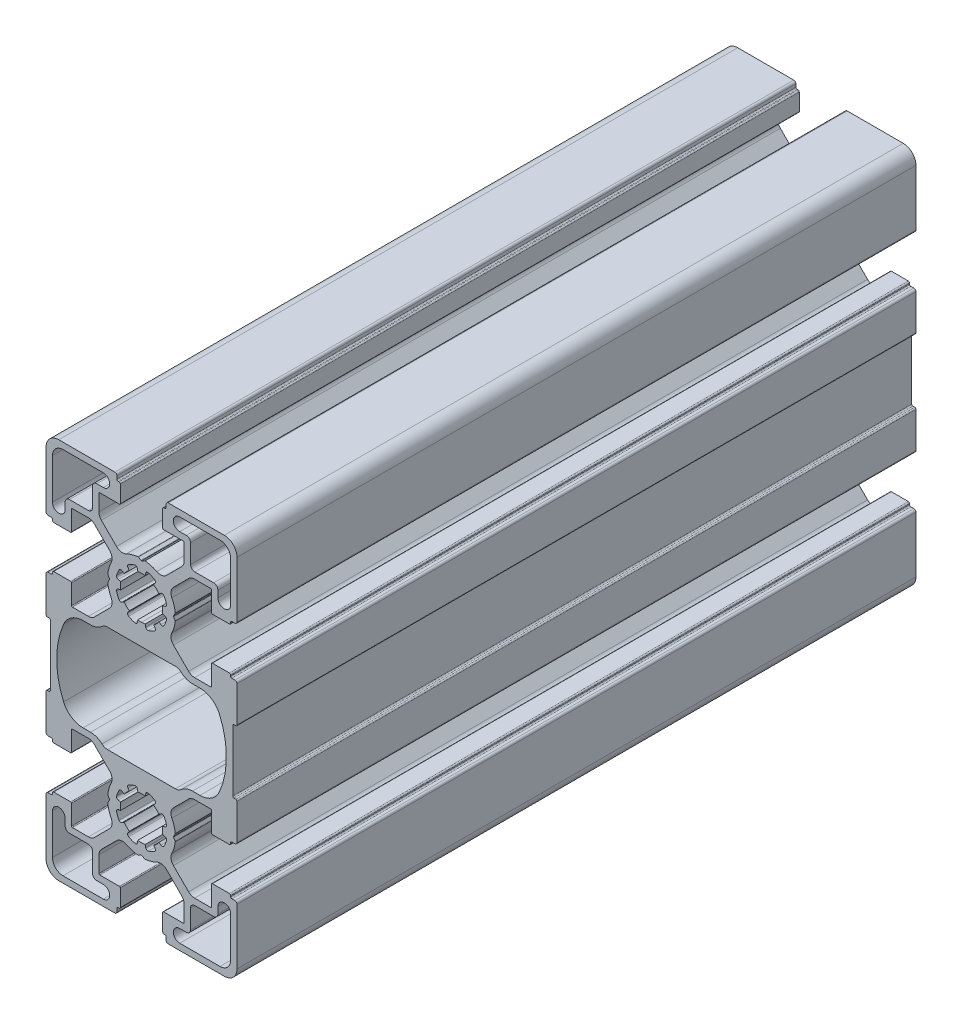
from build123d import *

# Parameters (mm, degrees)
BASE_EXTRUDE_DEPTH = 160


with BuildPart() as part:
    # Sketch1 → Base-Extrude (new body)
    with BuildSketch(Plane.XY):
        with BuildLine():
            Line((-0.740836116, 30.427758634), (-0.102763251, 30.059367406))
            ThreePointArc((-0.102763251, 30.059367406), (-0.053312326, 30.038169391), (0, 30.030920546))
            ThreePointArc((0, 30.030920546), (0.053312326, 30.038169391), (0.102763251, 30.059367406))
            Line((0.102763251, 30.059367406), (0.740836116, 30.427758634))
            ThreePointArc((0.740836116, 30.427758634), (0.799576237, 30.450250726), (0.86239711, 30.453386662))
            ThreePointArc((0.86239711, 30.453386662), (2.260568883, 30.173971094), (3.586933491, 29.650793982))
            ThreePointArc((3.586933491, 29.650793982), (4.802749757, 29.46409935), (5.897874663, 30.024247115))
            Line((5.897874663, 30.024247115), (9.464166852, 33.590539926))
            ThreePointArc((9.464166852, 33.590539926), (9.897712372, 34.239387492), (10.049953531, 35.004755059))
            Line((10.049953531, 35.004755059), (10.049953531, 38.799984208))
            ThreePointArc((10.049953531, 38.799984208), (9.991374345, 38.941406873), (9.84995168, 38.999986059))
            Line((9.84995168, 38.999986059), (5.199960681, 38.999986059))
            ThreePointArc((5.199960681, 38.999986059), (5.058538016, 39.058565245), (4.99995883, 39.199987909))
            Line((4.99995883, 39.199987909), (4.99995883, 43.199989085))
            ThreePointArc((4.99995883, 43.199989085), (5.087825998, 43.412119193), (5.299956106, 43.499986361))
            Line((5.299956106, 43.499986361), (5.499944988, 43.499986361))
            ThreePointArc((5.499944988, 43.499986361), (5.71207757, 43.587854553), (5.799945763, 43.799987136))
            Line((5.799945763, 43.799987136), (5.799945763, 44.500009803))
            ThreePointArc((5.799945763, 44.500009803), (5.946392263, 44.85356293), (6.29994539, 45.00000943))
            Line((6.29994539, 45.00000943), (19.499955001, 45.00000943))
            ThreePointArc((19.499955001, 45.00000943), (21.62127376, 44.12133043), (22.49995276, 42.000011671))
            Line((22.49995276, 42.000011671), (22.49995276, 28.79998913))
            ThreePointArc((22.49995276, 28.79998913), (22.353506233, 28.446435977), (21.999953058, 28.299989504))
            Line((21.999953058, 28.299989504), (21.299938888, 28.29998961))
            ThreePointArc((21.299938888, 28.29998961), (21.087805922, 28.212121287), (20.999937567, 27.999988334))
            Line((20.999937567, 27.999988334), (20.999937567, 27.799995477))
            ThreePointArc((20.999937567, 27.799995477), (20.912069081, 27.587862187), (20.699935791, 27.499993701))
            Line((20.699935791, 27.499993701), (16.699935313, 27.499993701))
            ThreePointArc((16.699935313, 27.499993701), (16.558515235, 27.558571815), (16.499937121, 27.699991893))
            Line((16.499937121, 27.699991893), (16.499937121, 32.34998995))
            ThreePointArc((16.499937121, 32.34998995), (16.441358961, 32.49141014), (16.299938771, 32.549988301))
            Line((16.299938771, 32.549988301), (12.504708373, 32.549988301))
            ThreePointArc((12.504708373, 32.549988301), (11.739340597, 32.397747212), (11.090493085, 31.964201264))
            Line((11.090493085, 31.964201264), (7.524203235, 28.397912415))
            ThreePointArc((7.524203235, 28.397912415), (6.964033778, 27.302784051), (7.150720073, 26.086953396))
            ThreePointArc((7.150720073, 26.086953396), (7.673896729, 24.760597365), (7.953313252, 23.362434091))
            ThreePointArc((7.953313252, 23.362434091), (7.950176411, 23.299610003), (7.927682437, 23.240867116))
            Line((7.927682437, 23.240867116), (7.557669192, 22.599991424))
            ThreePointArc((7.557669192, 22.599991424), (7.530873485, 22.4999893), (7.557669192, 22.399987177))
            Line((7.557669192, 22.399987177), (7.927682978, 21.759110548))
            ThreePointArc((7.927682978, 21.759110548), (7.9501755, 21.700371448), (7.953312133, 21.637551412))
            ThreePointArc((7.953312133, 21.637551412), (7.673894832, 20.239384934), (7.150716902, 18.913025864))
            ThreePointArc((7.150716902, 18.913025864), (6.964030761, 17.697197224), (7.524198948, 16.602070473))
            Line((7.524198948, 16.602070473), (11.090489343, 13.035778079))
            ThreePointArc((11.090489343, 13.035778079), (11.739337223, 12.602231588), (12.504705581, 12.449990301))
            Line((12.504705581, 12.449990301), (16.299936771, 12.449990301))
            ThreePointArc((16.299936771, 12.449990301), (16.441358375, 12.508569047), (16.499937121, 12.649990651))
            Line((16.499937121, 12.649990651), (16.499937121, 17.29998595))
            ThreePointArc((16.499937121, 17.29998595), (16.558515575, 17.441406847), (16.699936472, 17.499985301))
            Line((16.699936472, 17.499985301), (20.699937845, 17.499985301))
            ThreePointArc((20.699937845, 17.499985301), (20.912069392, 17.412117523), (20.999937121, 17.199985957))
            Line((20.999937121, 17.199985957), (20.999937076, 16.999997645))
            ThreePointArc((20.999937076, 16.999997645), (21.087804805, 16.787866078), (21.299936352, 16.699998301))
            Line((21.299936352, 16.699998301), (21.999952596, 16.699998301))
            ThreePointArc((21.999952596, 16.699998301), (22.353506326, 16.553551551), (22.499953076, 16.199997821))
            Line((22.499953076, 16.199997821), (22.499953076, 7.799999276))
            ThreePointArc((22.499953076, 7.799999276), (22.412085322, 7.587867754), (22.1999538, 7.5))
            Line((22.1999538, 7.5), (21.799954836, 7.5))
            ThreePointArc((21.799954836, 7.5), (21.58782296, 7.4121321), (21.49995506, 7.200000224))
            Line((21.49995506, 7.200000224), (21.49995506, -7.200000224))
            ThreePointArc((21.49995506, -7.200000224), (21.58782296, -7.4121321), (21.799954836, -7.5))
            Line((21.799954836, -7.5), (22.1999538, -7.5))
            ThreePointArc((22.1999538, -7.5), (22.412085322, -7.587867754), (22.499953076, -7.799999276))
            Line((22.499953076, -7.799999276), (22.499953076, -16.199997821))
            ThreePointArc((22.499953076, -16.199997821), (22.353506326, -16.553551551), (21.999952596, -16.699998301))
            Line((21.999952596, -16.699998301), (21.299936352, -16.699998301))
            ThreePointArc((21.299936352, -16.699998301), (21.087804805, -16.787866078), (20.999937076, -16.999997645))
            Line((20.999937076, -16.999997645), (20.999937121, -17.199985957))
            ThreePointArc((20.999937121, -17.199985957), (20.912069392, -17.412117523), (20.699937845, -17.499985301))
            Line((20.699937845, -17.499985301), (16.699936472, -17.499985301))
            ThreePointArc((16.699936472, -17.499985301), (16.558515575, -17.441406847), (16.499937121, -17.29998595))
            Line((16.499937121, -17.29998595), (16.499937121, -12.649990651))
            ThreePointArc((16.499937121, -12.649990651), (16.441358375, -12.508569047), (16.299936771, -12.449990301))
            Line((16.299936771, -12.449990301), (12.504705581, -12.449990301))
            ThreePointArc((12.504705581, -12.449990301), (11.739337223, -12.602231588), (11.090489343, -13.035778079))
            Line((11.090489343, -13.035778079), (7.524198948, -16.602070473))
            ThreePointArc((7.524198948, -16.602070473), (6.964030761, -17.697197224), (7.150716902, -18.913025864))
            ThreePointArc((7.150716902, -18.913025864), (7.673894832, -20.239384934), (7.953312133, -21.637551412))
            ThreePointArc((7.953312133, -21.637551412), (7.9501755, -21.700371448), (7.927682978, -21.759110548))
            Line((7.927682978, -21.759110548), (7.557669192, -22.399987177))
            ThreePointArc((7.557669192, -22.399987177), (7.530873485, -22.4999893), (7.557669192, -22.599991424))
            Line((7.557669192, -22.599991424), (7.927682437, -23.240867116))
            ThreePointArc((7.927682437, -23.240867116), (7.950176411, -23.299610003), (7.953313252, -23.362434091))
            ThreePointArc((7.953313252, -23.362434091), (7.673896729, -24.760597365), (7.150720073, -26.086953396))
            ThreePointArc((7.150720073, -26.086953396), (6.964033778, -27.302784051), (7.524203235, -28.397912415))
            Line((7.524203235, -28.397912415), (11.090493085, -31.964201264))
            ThreePointArc((11.090493085, -31.964201264), (11.739340597, -32.397747212), (12.504708373, -32.549988301))
            Line((12.504708373, -32.549988301), (16.299938771, -32.549988301))
            ThreePointArc((16.299938771, -32.549988301), (16.441358961, -32.49141014), (16.499937121, -32.34998995))
            Line((16.499937121, -32.34998995), (16.499937121, -27.699991893))
            ThreePointArc((16.499937121, -27.699991893), (16.558515235, -27.558571815), (16.699935313, -27.499993701))
            Line((16.699935313, -27.499993701), (20.699935791, -27.499993701))
            ThreePointArc((20.699935791, -27.499993701), (20.912069081, -27.587862187), (20.999937567, -27.799995477))
            Line((20.999937567, -27.799995477), (20.999937567, -27.999988334))
            ThreePointArc((20.999937567, -27.999988334), (21.087805922, -28.212121287), (21.299938888, -28.29998961))
            Line((21.299938888, -28.29998961), (21.999953058, -28.299989504))
            ThreePointArc((21.999953058, -28.299989504), (22.353506233, -28.446435977), (22.49995276, -28.79998913))
            Line((22.49995276, -28.79998913), (22.49995276, -42.000011671))
            ThreePointArc((22.49995276, -42.000011671), (21.62127376, -44.12133043), (19.499955001, -45.00000943))
            Line((19.499955001, -45.00000943), (6.29994539, -45.00000943))
            ThreePointArc((6.29994539, -45.00000943), (5.946392263, -44.85356293), (5.799945763, -44.500009803))
            Line((5.799945763, -44.500009803), (5.799945763, -43.799987136))
            ThreePointArc((5.799945763, -43.799987136), (5.71207757, -43.587854553), (5.499944988, -43.499986361))
            Line((5.499944988, -43.499986361), (5.299956106, -43.499986361))
            ThreePointArc((5.299956106, -43.499986361), (5.087825998, -43.412119193), (4.99995883, -43.199989085))
            Line((4.99995883, -43.199989085), (4.99995883, -39.199987909))
            ThreePointArc((4.99995883, -39.199987909), (5.058538016, -39.058565245), (5.199960681, -38.999986059))
            Line((5.199960681, -38.999986059), (9.84995168, -38.999986059))
            ThreePointArc((9.84995168, -38.999986059), (9.991374345, -38.941406873), (10.049953531, -38.799984208))
            Line((10.049953531, -38.799984208), (10.049953531, -35.004755059))
            ThreePointArc((10.049953531, -35.004755059), (9.897712372, -34.239387492), (9.464166852, -33.590539926))
            Line((9.464166852, -33.590539926), (5.897874663, -30.024247115))
            ThreePointArc((5.897874663, -30.024247115), (4.802749757, -29.46409935), (3.586933491, -29.650793982))
            ThreePointArc((3.586933491, -29.650793982), (2.260568883, -30.173971094), (0.86239711, -30.453386662))
            ThreePointArc((0.86239711, -30.453386662), (0.799576237, -30.450250726), (0.740836116, -30.427758634))
            Line((0.740836116, -30.427758634), (0.102763251, -30.059367406))
            ThreePointArc((0.102763251, -30.059367406), (0.053312326, -30.038169391), (0, -30.030920546))
            ThreePointArc((0, -30.030920546), (-0.053312326, -30.038169391), (-0.102763251, -30.059367406))
            Line((-0.102763251, -30.059367406), (-0.740836116, -30.427758634))
            ThreePointArc((-0.740836116, -30.427758634), (-0.799576237, -30.450250726), (-0.86239711, -30.453386662))
            ThreePointArc((-0.86239711, -30.453386662), (-2.260568883, -30.173971094), (-3.586933491, -29.650793982))
            ThreePointArc((-3.586933491, -29.650793982), (-4.802749757, -29.46409935), (-5.897874663, -30.024247115))
            Line((-5.897874663, -30.024247115), (-9.464166852, -33.590539926))
            ThreePointArc((-9.464166852, -33.590539926), (-9.897712372, -34.239387492), (-10.049953531, -35.004755059))
            Line((-10.049953531, -35.004755059), (-10.049953531, -38.799984208))
            ThreePointArc((-10.049953531, -38.799984208), (-9.991374345, -38.941406873), (-9.84995168, -38.999986059))
            Line((-9.84995168, -38.999986059), (-5.199960681, -38.999986059))
            ThreePointArc((-5.199960681, -38.999986059), (-5.058538016, -39.058565245), (-4.99995883, -39.199987909))
            Line((-4.99995883, -39.199987909), (-4.99995883, -43.199989085))
            ThreePointArc((-4.99995883, -43.199989085), (-5.087825998, -43.412119193), (-5.299956106, -43.499986361))
            Line((-5.299956106, -43.499986361), (-5.499944988, -43.499986361))
            ThreePointArc((-5.499944988, -43.499986361), (-5.71207757, -43.587854553), (-5.799945763, -43.799987136))
            Line((-5.799945763, -43.799987136), (-5.799945763, -44.500009803))
            ThreePointArc((-5.799945763, -44.500009803), (-5.946392263, -44.85356293), (-6.29994539, -45.00000943))
            Line((-6.29994539, -45.00000943), (-19.499955001, -45.00000943))
            ThreePointArc((-19.499955001, -45.00000943), (-21.62127376, -44.12133043), (-22.49995276, -42.000011671))
            Line((-22.49995276, -42.000011671), (-22.49995276, -28.79998913))
            ThreePointArc((-22.49995276, -28.79998913), (-22.353506233, -28.446435977), (-21.999953058, -28.299989504))
            Line((-21.999953058, -28.299989504), (-21.299938888, -28.29998961))
            ThreePointArc((-21.299938888, -28.29998961), (-21.087805922, -28.212121287), (-20.999937567, -27.999988334))
            Line((-20.999937567, -27.999988334), (-20.999937567, -27.799995477))
            ThreePointArc((-20.999937567, -27.799995477), (-20.912069081, -27.587862187), (-20.699935791, -27.499993701))
            Line((-20.699935791, -27.499993701), (-16.699935313, -27.499993701))
            ThreePointArc((-16.699935313, -27.499993701), (-16.558515235, -27.558571815), (-16.499937121, -27.699991893))
            Line((-16.499937121, -27.699991893), (-16.499937121, -32.34998995))
            ThreePointArc((-16.499937121, -32.34998995), (-16.441358961, -32.49141014), (-16.299938771, -32.549988301))
            Line((-16.299938771, -32.549988301), (-12.504708373, -32.549988301))
            ThreePointArc((-12.504708373, -32.549988301), (-11.739340597, -32.397747212), (-11.090493085, -31.964201264))
            Line((-11.090493085, -31.964201264), (-7.524203235, -28.397912415))
            ThreePointArc((-7.524203235, -28.397912415), (-6.964033778, -27.302784051), (-7.150720073, -26.086953396))
            ThreePointArc((-7.150720073, -26.086953396), (-7.673896729, -24.760597365), (-7.953313252, -23.362434091))
            ThreePointArc((-7.953313252, -23.362434091), (-7.950176411, -23.299610003), (-7.927682437, -23.240867116))
            Line((-7.927682437, -23.240867116), (-7.557669192, -22.599991424))
            ThreePointArc((-7.557669192, -22.599991424), (-7.530873485, -22.4999893), (-7.557669192, -22.399987177))
            Line((-7.557669192, -22.399987177), (-7.927682978, -21.759110548))
            ThreePointArc((-7.927682978, -21.759110548), (-7.9501755, -21.700371448), (-7.953312133, -21.637551412))
            ThreePointArc((-7.953312133, -21.637551412), (-7.673894832, -20.239384934), (-7.150716902, -18.913025864))
            ThreePointArc((-7.150716902, -18.913025864), (-6.964030761, -17.697197224), (-7.524198948, -16.602070473))
            Line((-7.524198948, -16.602070473), (-11.090489343, -13.035778079))
            ThreePointArc((-11.090489343, -13.035778079), (-11.739337223, -12.602231588), (-12.504705581, -12.449990301))
            Line((-12.504705581, -12.449990301), (-16.299936771, -12.449990301))
            ThreePointArc((-16.299936771, -12.449990301), (-16.441358375, -12.508569047), (-16.499937121, -12.649990651))
            Line((-16.499937121, -12.649990651), (-16.499937121, -17.29998595))
            ThreePointArc((-16.499937121, -17.29998595), (-16.558515575, -17.441406847), (-16.699936472, -17.499985301))
            Line((-16.699936472, -17.499985301), (-20.699937845, -17.499985301))
            ThreePointArc((-20.699937845, -17.499985301), (-20.912069392, -17.412117523), (-20.999937121, -17.199985957))
            Line((-20.999937121, -17.199985957), (-20.999937076, -16.999997645))
            ThreePointArc((-20.999937076, -16.999997645), (-21.087804805, -16.787866078), (-21.299936352, -16.699998301))
            Line((-21.299936352, -16.699998301), (-21.999952596, -16.699998301))
            ThreePointArc((-21.999952596, -16.699998301), (-22.353506326, -16.553551551), (-22.499953076, -16.199997821))
            Line((-22.499953076, -16.199997821), (-22.499953076, -7.799999276))
            ThreePointArc((-22.499953076, -7.799999276), (-22.412085322, -7.587867754), (-22.1999538, -7.5))
            Line((-22.1999538, -7.5), (-21.799954836, -7.5))
            ThreePointArc((-21.799954836, -7.5), (-21.58782296, -7.4121321), (-21.49995506, -7.200000224))
            Line((-21.49995506, -7.200000224), (-21.49995506, 7.200000224))
            ThreePointArc((-21.49995506, 7.200000224), (-21.58782296, 7.4121321), (-21.799954836, 7.5))
            Line((-21.799954836, 7.5), (-22.1999538, 7.5))
            ThreePointArc((-22.1999538, 7.5), (-22.412085322, 7.587867754), (-22.499953076, 7.799999276))
            Line((-22.499953076, 7.799999276), (-22.499953076, 16.199997821))
            ThreePointArc((-22.499953076, 16.199997821), (-22.353506326, 16.553551551), (-21.999952596, 16.699998301))
            Line((-21.999952596, 16.699998301), (-21.299936352, 16.699998301))
            ThreePointArc((-21.299936352, 16.699998301), (-21.087804805, 16.787866078), (-20.999937076, 16.999997645))
            Line((-20.999937076, 16.999997645), (-20.999937121, 17.199985957))
            ThreePointArc((-20.999937121, 17.199985957), (-20.912069392, 17.412117523), (-20.699937845, 17.499985301))
            Line((-20.699937845, 17.499985301), (-16.699936472, 17.499985301))
            ThreePointArc((-16.699936472, 17.499985301), (-16.558515575, 17.441406847), (-16.499937121, 17.29998595))
            Line((-16.499937121, 17.29998595), (-16.499937121, 12.649990651))
            ThreePointArc((-16.499937121, 12.649990651), (-16.441358375, 12.508569047), (-16.299936771, 12.449990301))
            Line((-16.299936771, 12.449990301), (-12.504705581, 12.449990301))
            ThreePointArc((-12.504705581, 12.449990301), (-11.739337223, 12.602231588), (-11.090489343, 13.035778079))
            Line((-11.090489343, 13.035778079), (-7.524198948, 16.602070473))
            ThreePointArc((-7.524198948, 16.602070473), (-6.964030761, 17.697197224), (-7.150716902, 18.913025864))
            ThreePointArc((-7.150716902, 18.913025864), (-7.673894832, 20.239384934), (-7.953312133, 21.637551412))
            ThreePointArc((-7.953312133, 21.637551412), (-7.9501755, 21.700371448), (-7.927682978, 21.759110548))
            Line((-7.927682978, 21.759110548), (-7.557669192, 22.399987177))
            ThreePointArc((-7.557669192, 22.399987177), (-7.530873485, 22.4999893), (-7.557669192, 22.599991424))
            Line((-7.557669192, 22.599991424), (-7.927682437, 23.240867116))
            ThreePointArc((-7.927682437, 23.240867116), (-7.950176411, 23.299610003), (-7.953313252, 23.362434091))
            ThreePointArc((-7.953313252, 23.362434091), (-7.673896729, 24.760597365), (-7.150720073, 26.086953396))
            ThreePointArc((-7.150720073, 26.086953396), (-6.964033778, 27.302784051), (-7.524203235, 28.397912415))
            Line((-7.524203235, 28.397912415), (-11.090493085, 31.964201264))
            ThreePointArc((-11.090493085, 31.964201264), (-11.739340597, 32.397747212), (-12.504708373, 32.549988301))
            Line((-12.504708373, 32.549988301), (-16.299938771, 32.549988301))
            ThreePointArc((-16.299938771, 32.549988301), (-16.441358961, 32.49141014), (-16.499937121, 32.34998995))
            Line((-16.499937121, 32.34998995), (-16.499937121, 27.699991893))
            ThreePointArc((-16.499937121, 27.699991893), (-16.558515235, 27.558571815), (-16.699935313, 27.499993701))
            Line((-16.699935313, 27.499993701), (-20.699935791, 27.499993701))
            ThreePointArc((-20.699935791, 27.499993701), (-20.912069081, 27.587862187), (-20.999937567, 27.799995477))
            Line((-20.999937567, 27.799995477), (-20.999937567, 27.999988334))
            ThreePointArc((-20.999937567, 27.999988334), (-21.087805922, 28.212121287), (-21.299938888, 28.29998961))
            Line((-21.299938888, 28.29998961), (-21.999953058, 28.299989504))
            ThreePointArc((-21.999953058, 28.299989504), (-22.353506233, 28.446435977), (-22.49995276, 28.79998913))
            Line((-22.49995276, 28.79998913), (-22.49995276, 42.000011671))
            ThreePointArc((-22.49995276, 42.000011671), (-21.62127376, 44.12133043), (-19.499955001, 45.00000943))
            Line((-19.499955001, 45.00000943), (-6.29994539, 45.00000943))
            ThreePointArc((-6.29994539, 45.00000943), (-5.946392263, 44.85356293), (-5.799945763, 44.500009803))
            Line((-5.799945763, 44.500009803), (-5.799945763, 43.799987136))
            ThreePointArc((-5.799945763, 43.799987136), (-5.71207757, 43.587854553), (-5.499944988, 43.499986361))
            Line((-5.499944988, 43.499986361), (-5.299956106, 43.499986361))
            ThreePointArc((-5.299956106, 43.499986361), (-5.087825998, 43.412119193), (-4.99995883, 43.199989085))
            Line((-4.99995883, 43.199989085), (-4.99995883, 39.199987909))
            ThreePointArc((-4.99995883, 39.199987909), (-5.058538016, 39.058565245), (-5.199960681, 38.999986059))
            Line((-5.199960681, 38.999986059), (-9.84995168, 38.999986059))
            ThreePointArc((-9.84995168, 38.999986059), (-9.991374345, 38.941406873), (-10.049953531, 38.799984208))
            Line((-10.049953531, 38.799984208), (-10.049953531, 35.004755059))
            ThreePointArc((-10.049953531, 35.004755059), (-9.897712372, 34.239387492), (-9.464166852, 33.590539926))
            Line((-9.464166852, 33.590539926), (-5.897874663, 30.024247115))
            ThreePointArc((-5.897874663, 30.024247115), (-4.802749757, 29.46409935), (-3.586933491, 29.650793982))
            ThreePointArc((-3.586933491, 29.650793982), (-2.260568883, 30.173971094), (-0.86239711, 30.453386662))
            ThreePointArc((-0.86239711, 30.453386662), (-0.799576237, 30.450250726), (-0.740836116, 30.427758634))
        make_face()
        with BuildLine():
            Line((-16.999956095, 34.049999843), (-12.549953601, 34.049999843))
            ThreePointArc((-12.549953601, 34.049999843), (-11.842847348, 34.342892843), (-11.549954348, 35.049999096))
            Line((-11.549954348, 35.049999096), (-11.549954348, 39.50000559))
            ThreePointArc((-11.549954348, 39.50000559), (-11.257061348, 40.207111843), (-10.549955095, 40.500004843))
            Line((-10.549955095, 40.500004843), (-8.999762348, 40.500004843))
            ThreePointArc((-8.999762348, 40.500004843), (-7.499762348, 42.000004843), (-8.999762348, 43.500004843))
            Line((-8.999762348, 43.500004843), (-18.499955348, 43.500004843))
            ThreePointArc((-18.499955348, 43.500004843), (-20.267722848, 42.767772343), (-20.999955348, 41.000004843))
            Line((-20.999955348, 41.000004843), (-20.999955348, 31.500004843))
            ThreePointArc((-20.999955348, 31.500004843), (-19.499955348, 30.000004843), (-17.999955348, 31.500004843))
            Line((-17.999955348, 31.500004843), (-17.999955348, 33.05000059))
            ThreePointArc((-17.999955348, 33.05000059), (-17.707062348, 33.757106843), (-16.999956095, 34.049999843))
        make_face(mode=Mode.SUBTRACT)
        with BuildLine():
            Line((-13.769413815, -10.9500015), (-12.004740125, -10.9500015))
            ThreePointArc((-12.004740125, -10.9500015), (-10.567151598, -11.217263271), (-9.321669706, -11.983334081))
            ThreePointArc((-9.321669706, -11.983334081), (-8.698928605, -12.366369581), (-7.980134162, -12.5000005))
            Line((-7.980134162, -12.5000005), (7.980134162, -12.5000005))
            ThreePointArc((7.980134162, -12.5000005), (8.698928605, -12.366369581), (9.321669706, -11.983334081))
            ThreePointArc((9.321669706, -11.983334081), (10.567151598, -11.217263271), (12.004740125, -10.9500015))
            Line((12.004740125, -10.9500015), (13.769413815, -10.9500015))
            ThreePointArc((13.769413815, -10.9500015), (16.515624223, -10.12831849), (18.359229348, -7.9333345))
            ThreePointArc((18.359229348, -7.9333345), (19.999977464, 0), (18.359229348, 7.9333345))
            ThreePointArc((18.359229348, 7.9333345), (16.515624223, 10.12831849), (13.769413815, 10.9500015))
            Line((13.769413815, 10.9500015), (12.004740125, 10.9500015))
            ThreePointArc((12.004740125, 10.9500015), (10.567151598, 11.217263271), (9.321669706, 11.983334081))
            ThreePointArc((9.321669706, 11.983334081), (8.698928605, 12.366369581), (7.980134162, 12.5000005))
            Line((7.980134162, 12.5000005), (-7.980134162, 12.5000005))
            ThreePointArc((-7.980134162, 12.5000005), (-8.698928605, 12.366369581), (-9.321669706, 11.983334081))
            ThreePointArc((-9.321669706, 11.983334081), (-10.567151598, 11.217263271), (-12.004740125, 10.9500015))
            Line((-12.004740125, 10.9500015), (-13.769413815, 10.9500015))
            ThreePointArc((-13.769413815, 10.9500015), (-16.515624223, 10.12831849), (-18.359229348, 7.9333345))
            ThreePointArc((-18.359229348, 7.9333345), (-19.999977464, 0), (-18.359229348, -7.9333345))
            ThreePointArc((-18.359229348, -7.9333345), (-16.515624223, -10.12831849), (-13.769413815, -10.9500015))
        make_face(mode=Mode.SUBTRACT)
        with BuildLine():
            Line((-0.968529348, -17.007114843), (-0.868229348, -17.575962843))
            ThreePointArc((-0.868229348, -17.575962843), (-0.435772972, -17.51902743), (0, -17.499999169))
            ThreePointArc((0, -17.499999169), (0.435772972, -17.51902743), (0.868229348, -17.575962843))
            Line((0.868229348, -17.575962843), (0.968529348, -17.007114843))
            ThreePointArc((0.968529348, -17.007114843), (1.192733474, -16.671952766), (1.591376348, -16.611248843))
            ThreePointArc((1.591376348, -16.611248843), (2.334343828, -16.864339169), (3.038663111, -17.210734515))
            ThreePointArc((3.038663111, -17.210734515), (3.27762112, -17.535538492), (3.199165111, -17.931067515))
            Line((3.199165111, -17.931067515), (2.867853111, -18.404235515))
            ThreePointArc((2.867853111, -18.404235515), (3.5355031, -18.964458807), (4.095729111, -19.632106515))
            Line((4.095729111, -19.632106515), (4.568897111, -19.300792515))
            ThreePointArc((4.568897111, -19.300792515), (4.964426393, -19.222334926), (5.289232111, -19.461291515))
            ThreePointArc((5.289232111, -19.461291515), (5.635635578, -20.165626945), (5.888730249, -20.908612037))
            ThreePointArc((5.888730249, -20.908612037), (5.82802952, -21.307253357), (5.492872249, -21.531461037))
            Line((5.492872249, -21.531461037), (4.924014249, -21.631772037))
            ThreePointArc((4.924014249, -21.631772037), (4.99997462, -22.500016159), (4.924011448, -23.368260037))
            Line((4.924011448, -23.368260037), (5.492862448, -23.468556037))
            ThreePointArc((5.492862448, -23.468556037), (5.828026088, -23.692760546), (5.888729448, -24.091405037))
            ThreePointArc((5.888729448, -24.091405037), (5.635639286, -24.834373492), (5.289243804, -25.538693679))
            ThreePointArc((5.289243804, -25.538693679), (4.964440768, -25.777653467), (4.568910804, -25.699200679))
            Line((4.568910804, -25.699200679), (4.095733804, -25.367879679))
            ThreePointArc((4.095733804, -25.367879679), (3.535509681, -26.035528129), (2.867861616, -26.59575271))
            Line((2.867861616, -26.59575271), (3.199182534, -27.068929022))
            ThreePointArc((3.199182534, -27.068929022), (3.277639343, -27.464459244), (3.038681534, -27.789265022))
            ThreePointArc((3.038681534, -27.789265022), (2.334347014, -28.13567085), (1.591362534, -28.388768022))
            ThreePointArc((1.591362534, -28.388768022), (1.192721254, -28.328062724), (0.968517534, -27.992902022))
            Line((0.968517534, -27.992902022), (0.868211534, -27.424046022))
            ThreePointArc((0.868211534, -27.424046022), (0, -27.500002349), (-0.868211534, -27.424046022))
            Line((-0.868211534, -27.424046022), (-0.968517534, -27.992902022))
            ThreePointArc((-0.968517534, -27.992902022), (-1.192721254, -28.328062724), (-1.591362534, -28.388768022))
            ThreePointArc((-1.591362534, -28.388768022), (-2.334347014, -28.13567085), (-3.038681534, -27.789265022))
            ThreePointArc((-3.038681534, -27.789265022), (-3.277639343, -27.464459244), (-3.199182534, -27.068929022))
            Line((-3.199182534, -27.068929022), (-2.867861616, -26.59575271))
            ThreePointArc((-2.867861616, -26.59575271), (-3.535509681, -26.035528129), (-4.095733804, -25.367879679))
            Line((-4.095733804, -25.367879679), (-4.568910804, -25.699200679))
            ThreePointArc((-4.568910804, -25.699200679), (-4.964440768, -25.777653467), (-5.289243804, -25.538693679))
            ThreePointArc((-5.289243804, -25.538693679), (-5.635639286, -24.834373492), (-5.888729448, -24.091405037))
            ThreePointArc((-5.888729448, -24.091405037), (-5.828026088, -23.692760546), (-5.492862448, -23.468556037))
            Line((-5.492862448, -23.468556037), (-4.924011448, -23.368260037))
            ThreePointArc((-4.924011448, -23.368260037), (-4.99997462, -22.500016159), (-4.924014249, -21.631772037))
            Line((-4.924014249, -21.631772037), (-5.492872249, -21.531461037))
            ThreePointArc((-5.492872249, -21.531461037), (-5.82802952, -21.307253357), (-5.888730249, -20.908612037))
            ThreePointArc((-5.888730249, -20.908612037), (-5.635635578, -20.165626945), (-5.289232111, -19.461291515))
            ThreePointArc((-5.289232111, -19.461291515), (-4.964426393, -19.222334926), (-4.568897111, -19.300792515))
            Line((-4.568897111, -19.300792515), (-4.095729111, -19.632106515))
            ThreePointArc((-4.095729111, -19.632106515), (-3.5355031, -18.964458807), (-2.867853111, -18.404235515))
            Line((-2.867853111, -18.404235515), (-3.199165111, -17.931067515))
            ThreePointArc((-3.199165111, -17.931067515), (-3.27762112, -17.535538492), (-3.038663111, -17.210734515))
            ThreePointArc((-3.038663111, -17.210734515), (-2.334343828, -16.864339169), (-1.591376348, -16.611248843))
            ThreePointArc((-1.591376348, -16.611248843), (-1.192733474, -16.671952766), (-0.968529348, -17.007114843))
        make_face(mode=Mode.SUBTRACT)
        with BuildLine():
            Line((-11.549954348, -35.049999096), (-11.549954348, -39.50000559))
            ThreePointArc((-11.549954348, -39.50000559), (-11.257061348, -40.207111843), (-10.549955095, -40.500004843))
            Line((-10.549955095, -40.500004843), (-8.999762348, -40.500004843))
            ThreePointArc((-8.999762348, -40.500004843), (-7.499762348, -42.000004843), (-8.999762348, -43.500004843))
            Line((-8.999762348, -43.500004843), (-18.499955348, -43.500004843))
            ThreePointArc((-18.499955348, -43.500004843), (-20.267722848, -42.767772343), (-20.999955348, -41.000004843))
            Line((-20.999955348, -41.000004843), (-20.999955348, -31.500004843))
            ThreePointArc((-20.999955348, -31.500004843), (-19.499955348, -30.000004843), (-17.999955348, -31.500004843))
            Line((-17.999955348, -31.500004843), (-17.999955348, -33.05000059))
            ThreePointArc((-17.999955348, -33.05000059), (-17.707062348, -33.757106843), (-16.999956095, -34.049999843))
            Line((-16.999956095, -34.049999843), (-12.549953601, -34.049999843))
            ThreePointArc((-12.549953601, -34.049999843), (-11.842847348, -34.342892843), (-11.549954348, -35.049999096))
        make_face(mode=Mode.SUBTRACT)
        with BuildLine():
            Line((0.968529348, 17.007114843), (0.868229348, 17.575962843))
            ThreePointArc((0.868229348, 17.575962843), (0.435772972, 17.51902743), (0, 17.499999169))
            ThreePointArc((0, 17.499999169), (-0.435772972, 17.51902743), (-0.868229348, 17.575962843))
            Line((-0.868229348, 17.575962843), (-0.968529348, 17.007114843))
            ThreePointArc((-0.968529348, 17.007114843), (-1.192733474, 16.671952766), (-1.591376348, 16.611248843))
            ThreePointArc((-1.591376348, 16.611248843), (-2.334343828, 16.864339169), (-3.038663111, 17.210734515))
            ThreePointArc((-3.038663111, 17.210734515), (-3.27762112, 17.535538492), (-3.199165111, 17.931067515))
            Line((-3.199165111, 17.931067515), (-2.867853111, 18.404235515))
            ThreePointArc((-2.867853111, 18.404235515), (-3.5355031, 18.964458807), (-4.095729111, 19.632106515))
            Line((-4.095729111, 19.632106515), (-4.568897111, 19.300792515))
            ThreePointArc((-4.568897111, 19.300792515), (-4.964426393, 19.222334926), (-5.289232111, 19.461291515))
            ThreePointArc((-5.289232111, 19.461291515), (-5.635635578, 20.165626945), (-5.888730249, 20.908612037))
            ThreePointArc((-5.888730249, 20.908612037), (-5.82802952, 21.307253357), (-5.492872249, 21.531461037))
            Line((-5.492872249, 21.531461037), (-4.924014249, 21.631772037))
            ThreePointArc((-4.924014249, 21.631772037), (-4.99997462, 22.500016159), (-4.924011448, 23.368260037))
            Line((-4.924011448, 23.368260037), (-5.492862448, 23.468556037))
            ThreePointArc((-5.492862448, 23.468556037), (-5.828026088, 23.692760546), (-5.888729448, 24.091405037))
            ThreePointArc((-5.888729448, 24.091405037), (-5.635639286, 24.834373492), (-5.289243804, 25.538693679))
            ThreePointArc((-5.289243804, 25.538693679), (-4.964440768, 25.777653467), (-4.568910804, 25.699200679))
            Line((-4.568910804, 25.699200679), (-4.095733804, 25.367879679))
            ThreePointArc((-4.095733804, 25.367879679), (-3.535509681, 26.035528129), (-2.867861616, 26.59575271))
            Line((-2.867861616, 26.59575271), (-3.199182534, 27.068929022))
            ThreePointArc((-3.199182534, 27.068929022), (-3.277639343, 27.464459244), (-3.038681534, 27.789265022))
            ThreePointArc((-3.038681534, 27.789265022), (-2.334347014, 28.13567085), (-1.591362534, 28.388768022))
            ThreePointArc((-1.591362534, 28.388768022), (-1.192721254, 28.328062724), (-0.968517534, 27.992902022))
            Line((-0.968517534, 27.992902022), (-0.868211534, 27.424046022))
            ThreePointArc((-0.868211534, 27.424046022), (0, 27.500002349), (0.868211534, 27.424046022))
            Line((0.868211534, 27.424046022), (0.968517534, 27.992902022))
            ThreePointArc((0.968517534, 27.992902022), (1.192721254, 28.328062724), (1.591362534, 28.388768022))
            ThreePointArc((1.591362534, 28.388768022), (2.334347014, 28.13567085), (3.038681534, 27.789265022))
            ThreePointArc((3.038681534, 27.789265022), (3.277639343, 27.464459244), (3.199182534, 27.068929022))
            Line((3.199182534, 27.068929022), (2.867861616, 26.59575271))
            ThreePointArc((2.867861616, 26.59575271), (3.535509681, 26.035528129), (4.095733804, 25.367879679))
            Line((4.095733804, 25.367879679), (4.568910804, 25.699200679))
            ThreePointArc((4.568910804, 25.699200679), (4.964440768, 25.777653467), (5.289243804, 25.538693679))
            ThreePointArc((5.289243804, 25.538693679), (5.635639286, 24.834373492), (5.888729448, 24.091405037))
            ThreePointArc((5.888729448, 24.091405037), (5.828026088, 23.692760546), (5.492862448, 23.468556037))
            Line((5.492862448, 23.468556037), (4.924011448, 23.368260037))
            ThreePointArc((4.924011448, 23.368260037), (4.99997462, 22.500016159), (4.924014249, 21.631772037))
            Line((4.924014249, 21.631772037), (5.492872249, 21.531461037))
            ThreePointArc((5.492872249, 21.531461037), (5.82802952, 21.307253357), (5.888730249, 20.908612037))
            ThreePointArc((5.888730249, 20.908612037), (5.635635578, 20.165626945), (5.289232111, 19.461291515))
            ThreePointArc((5.289232111, 19.461291515), (4.964426393, 19.222334926), (4.568897111, 19.300792515))
            Line((4.568897111, 19.300792515), (4.095729111, 19.632106515))
            ThreePointArc((4.095729111, 19.632106515), (3.5355031, 18.964458807), (2.867853111, 18.404235515))
            Line((2.867853111, 18.404235515), (3.199165111, 17.931067515))
            ThreePointArc((3.199165111, 17.931067515), (3.27762112, 17.535538492), (3.038663111, 17.210734515))
            ThreePointArc((3.038663111, 17.210734515), (2.334343828, 16.864339169), (1.591376348, 16.611248843))
            ThreePointArc((1.591376348, 16.611248843), (1.192733474, 16.671952766), (0.968529348, 17.007114843))
        make_face(mode=Mode.SUBTRACT)
        with BuildLine():
            Line((16.999956095, -34.049999843), (12.549953601, -34.049999843))
            ThreePointArc((12.549953601, -34.049999843), (11.842847348, -34.342892843), (11.549954348, -35.049999096))
            Line((11.549954348, -35.049999096), (11.549954348, -39.50000559))
            ThreePointArc((11.549954348, -39.50000559), (11.257061348, -40.207111843), (10.549955095, -40.500004843))
            Line((10.549955095, -40.500004843), (8.999762348, -40.500004843))
            ThreePointArc((8.999762348, -40.500004843), (7.499762348, -42.000004843), (8.999762348, -43.500004843))
            Line((8.999762348, -43.500004843), (18.499955348, -43.500004843))
            ThreePointArc((18.499955348, -43.500004843), (20.267722848, -42.767772343), (20.999955348, -41.000004843))
            Line((20.999955348, -41.000004843), (20.999955348, -31.500004843))
            ThreePointArc((20.999955348, -31.500004843), (19.499955348, -30.000004843), (17.999955348, -31.500004843))
            Line((17.999955348, -31.500004843), (17.999955348, -33.05000059))
            ThreePointArc((17.999955348, -33.05000059), (17.707062348, -33.757106843), (16.999956095, -34.049999843))
        make_face(mode=Mode.SUBTRACT)
        with BuildLine():
            Line((11.549954348, 35.049999096), (11.549954348, 39.50000559))
            ThreePointArc((11.549954348, 39.50000559), (11.257061348, 40.207111843), (10.549955095, 40.500004843))
            Line((10.549955095, 40.500004843), (8.999762348, 40.500004843))
            ThreePointArc((8.999762348, 40.500004843), (7.499762348, 42.000004843), (8.999762348, 43.500004843))
            Line((8.999762348, 43.500004843), (18.499955348, 43.500004843))
            ThreePointArc((18.499955348, 43.500004843), (20.267722848, 42.767772343), (20.999955348, 41.000004843))
            Line((20.999955348, 41.000004843), (20.999955348, 31.500004843))
            ThreePointArc((20.999955348, 31.500004843), (19.499955348, 30.000004843), (17.999955348, 31.500004843))
            Line((17.999955348, 31.500004843), (17.999955348, 33.05000059))
            ThreePointArc((17.999955348, 33.05000059), (17.707062348, 33.757106843), (16.999956095, 34.049999843))
            Line((16.999956095, 34.049999843), (12.549953601, 34.049999843))
            ThreePointArc((12.549953601, 34.049999843), (11.842847348, 34.342892843), (11.549954348, 35.049999096))
        make_face(mode=Mode.SUBTRACT)
    extrude(amount=-BASE_EXTRUDE_DEPTH)


solid = part.part
